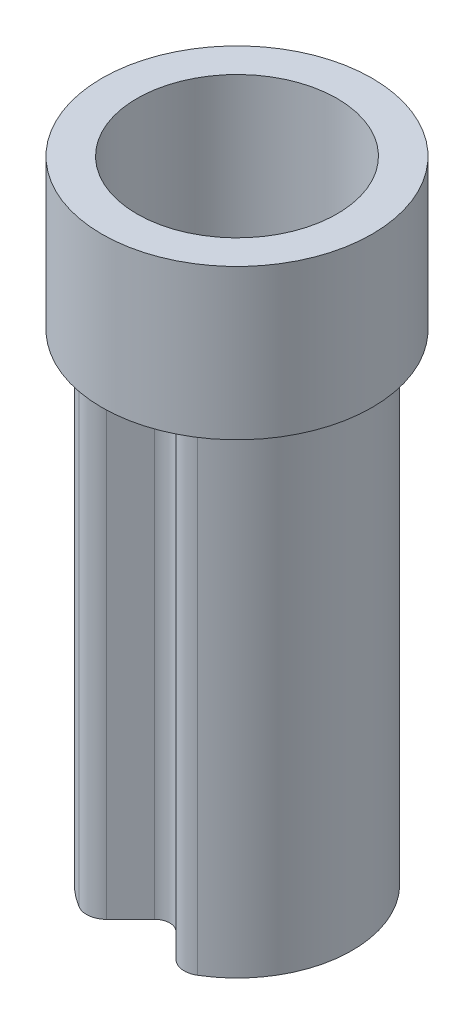
from build123d import *

# Parameters (mm, degrees)
BOSS_EXTRUDE1_DEPTH = 4.8
FILLET1_R           = 0.05
FILLET2_R           = 0.2
SKETCH2_R           = 1.35
SKETCH2_R_2         = 1
BOSS_EXTRUDE2_DEPTH = 1.5


with BuildPart() as part:
    # Sketch1 → Boss-Extrude1 (new body)
    with BuildSketch(Plane(origin=(0, 0, 0), x_dir=(1, 0, 0), z_dir=(0, 1, 0))):
        with BuildLine():
            Line((-0.448807004, -1.058807004), (-0.106066017, -0.716066017))
            ThreePointArc((-0.106066017, -0.716066017), (0, -0.672132034), (0.106066017, -0.716066017))
            Line((0.106066017, -0.716066017), (0.448807004, -1.058807004))
            ThreePointArc((0.448807004, -1.058807004), (0, 1.15), (-0.448807004, -1.058807004))
        make_face()
        with BuildLine():
            Line((-0.479612457, -0.877480422), (-0.212132034, -0.61))
            ThreePointArc((-0.212132034, -0.61), (0, -0.522132034), (0.212132034, -0.61))
            Line((0.212132034, -0.61), (0.479612457, -0.877480422))
            ThreePointArc((0.479612457, -0.877480422), (0, 1), (-0.479612457, -0.877480422))
        make_face(mode=Mode.SUBTRACT)
    extrude(amount=BOSS_EXTRUDE1_DEPTH)

    # Fillet1
    fillet1_edges = [part.edges().sort_by_distance(p)[0] for p in [
        (0.479612457, 2.4, 0.877480422),
        (-0.479612457, 2.4, 0.877480422),
    ]]
    fillet(fillet1_edges, radius=FILLET1_R)

    # Fillet2
    fillet2_edges = [part.edges().sort_by_distance(p)[0] for p in [
        (-0.448807004, 2.4, 1.058807004),
        (0.448807004, 2.4, 1.058807004),
    ]]
    fillet(fillet2_edges, radius=FILLET2_R)

    # Sketch2 → Boss-Extrude2 (add)
    with BuildSketch(Plane(origin=(0, 4.8, 0), x_dir=(1, 0, 0), z_dir=(0, 1, 0))):
        Circle(SKETCH2_R)
        Circle(SKETCH2_R_2, mode=Mode.SUBTRACT)
    extrude(amount=BOSS_EXTRUDE2_DEPTH)


solid = part.part
